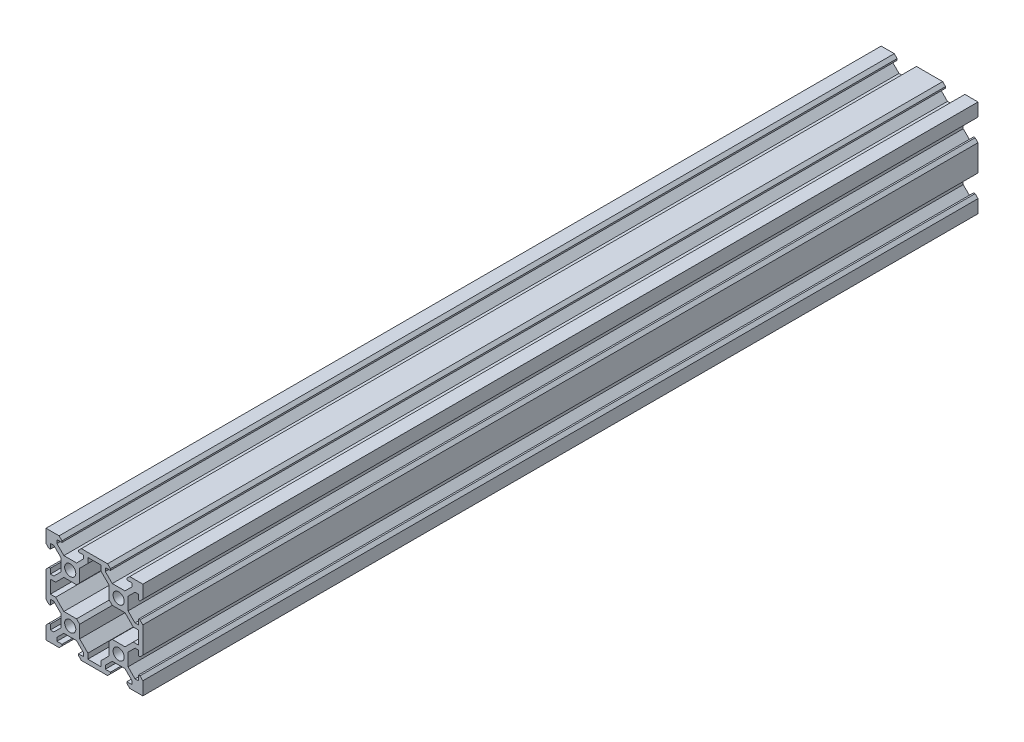
from build123d import *

# Parameters (mm, degrees)
SKETCH1_W           = 40
SKETCH1_H           = 40
BOSS_EXTRUDE1_DEPTH = 345
SKETCH2_R           = 2.3
CUT_EXTRUDE1_DEPTH  = 345
CUT_EXTRUDE2_DEPTH  = 345


with BuildPart() as part:
    # Sketch1 → Boss-Extrude1 (new body)
    with BuildSketch(Plane.XY):
        with Locations((20, 20)):
            Rectangle(SKETCH1_W, SKETCH1_H)
    extrude(amount=-BOSS_EXTRUDE1_DEPTH)

    # Sketch2 → Cut-Extrude1 (cut)
    with BuildSketch(Plane.XY):
        with Locations((10, 30)):
            Circle(SKETCH2_R)
        with Locations((30, 30)):
            Circle(SKETCH2_R)
        with Locations((30, 10)):
            Circle(SKETCH2_R)
        with Locations((10, 10)):
            Circle(SKETCH2_R)
        Polygon((6.605, 38.815), (6.605, 38.2), (4.5, 38.2), (4.5, 36.772792206), (7.372792206, 33.9), (12.627207794, 33.9), (15.5, 36.772792206), (15.5, 38.2), (13.395, 38.2), (13.395, 38.815), (14.58, 40), (5.42, 40), align=None)
        Polygon((26.605, 38.815), (25.42, 40), (34.58, 40), (33.395, 38.815), (33.395, 38.2), (35.5, 38.2), (35.5, 36.772792206), (32.627207794, 33.9), (27.372792206, 33.9), (24.5, 36.772792206), (24.5, 38.2), (26.605, 38.2), align=None)
        Polygon((26.605, 1.8), (26.605, 1.185), (25.42, 0), (34.58, 0), (33.395, 1.185), (33.395, 1.8), (35.5, 1.8), (35.5, 3.227207794), (32.627207794, 6.1), (27.372792206, 6.1), (24.5, 3.227207794), (24.5, 1.8), align=None)
        Polygon((13.395, 1.185), (14.58, 0), (5.42, 0), (6.605, 1.185), (6.605, 1.8), (4.5, 1.8), (4.5, 3.227207794), (7.372792206, 6.1), (12.627207794, 6.1), (15.5, 3.227207794), (15.5, 1.8), (13.395, 1.8), align=None)
        Polygon((1.8, 13.395), (1.185, 13.395), (0, 14.58), (0, 5.42), (1.185, 6.605), (1.8, 6.605), (1.8, 4.5), (3.227207794, 4.5), (6.1, 7.372792206), (6.1, 12.627207794), (3.227207794, 15.5), (1.8, 15.5), align=None)
        Polygon((1.185, 26.605), (0, 25.42), (0, 34.58), (1.185, 33.395), (1.8, 33.395), (1.8, 35.5), (3.227207794, 35.5), (6.1, 32.627207794), (6.1, 27.372792206), (3.227207794, 24.5), (1.8, 24.5), (1.8, 26.605), align=None)
        Polygon((38.2, 15.5), (38.2, 13.395), (38.815, 13.395), (40, 14.58), (40, 5.42), (38.815, 6.605), (38.2, 6.605), (38.2, 4.5), (36.772792206, 4.5), (33.9, 7.372792206), (33.9, 12.627207794), (36.772792206, 15.5), align=None)
        Polygon((38.2, 26.605), (38.815, 26.605), (40, 25.42), (40, 34.58), (38.815, 33.395), (38.2, 33.395), (38.2, 35.5), (36.772792206, 35.5), (33.9, 32.627207794), (33.9, 27.372792206), (36.772792206, 24.5), (38.2, 24.5), align=None)
    extrude(amount=-CUT_EXTRUDE1_DEPTH, mode=Mode.SUBTRACT)

    # Sketch3 → Cut-Extrude2 (cut)
    with BuildSketch(Plane.XY):
        Polygon((17.3, 38.2), (22.7, 38.2), (22.7, 36.027207794), (26.1, 32.627207794), (26.1, 27.372792206), (27.372792206, 26.1), (32.627207794, 26.1), (36.027207794, 22.7), (38.2, 22.7), (38.2, 17.3), (36.027207794, 17.3), (32.627207794, 13.9), (27.372792206, 13.9), (26.1, 12.627207794), (26.1, 7.372792206), (22.7, 3.972792206), (22.7, 1.8), (17.3, 1.8), (17.3, 3.972792206), (13.9, 7.372792206), (13.9, 12.627207794), (12.627207794, 13.9), (7.372792206, 13.9), (3.972792206, 17.3), (1.8, 17.3), (1.8, 22.7), (3.972792206, 22.7), (7.372792206, 26.1), (12.627207794, 26.1), (13.9, 27.372792206), (13.9, 32.627207794), (17.3, 36.027207794), align=None)
    extrude(amount=-CUT_EXTRUDE2_DEPTH, mode=Mode.SUBTRACT)


solid = part.part
